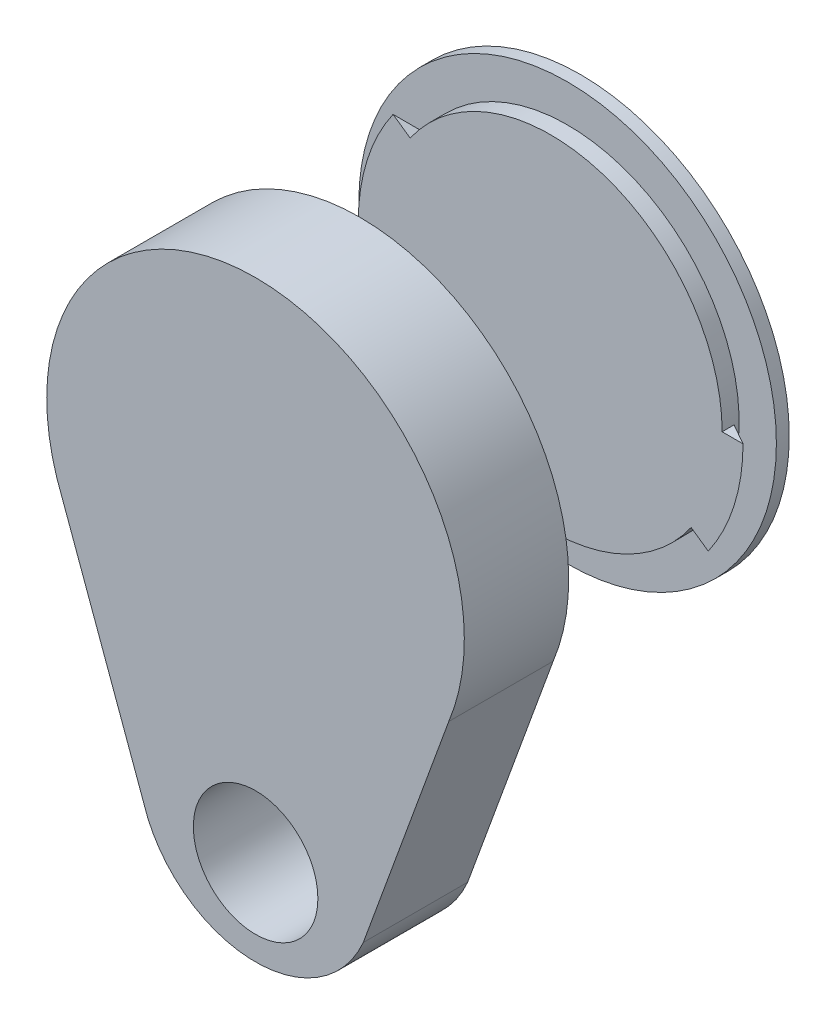
from build123d import *

# Parameters (mm, degrees)
BOSS_EXTRU_4_DEPTH           = 7
ESQUISSE11_R                 = 4.175305872
ENL_V_MAT_EXTRU_2_DEPTH      = 7
R_VOLUTION3_ANGLE            = 35
R_P_TITION_CIRCULAIRE1_COUNT = 2
R_VOLUTION4_ANGLE            = 140
R_P_TITION_CIRCULAIRE2_COUNT = 2


with BuildPart() as part:
    # Esquisse1 → Révolution1 (revolve)
    with BuildSketch(Plane(origin=(1.309044262, 0, 0), x_dir=(1, 0, 0), z_dir=(0, 1, 0))):
        Polygon((0.253488225, -3.046040946), (-13.746511775, -3.046040946), (-13.746511775, 3.953959054), (-12.746511775, 3.953959054), (-12.746511775, 3.442939457), (-12.746511775, 2.953959054), (-12.746511775, -2.046040946), (0.253488225, -2.046040946), align=None)
    revolve(axis=Axis((1.562532487, 0, 2.046040946), (0, 0, 1)))

    # Esquisse10 → Boss.-Extru.4 (add)
    with BuildSketch(Plane.XY.offset(3.046040946)):
        with BuildLine():
            Line((14.88883966, -4.290633652), (8.788835843, -21))
            ThreePointArc((8.788835843, -21), (1.562532487, -25.748246952), (-5.663770869, -21))
            Line((-5.663770869, -21), (-11.763774686, -4.290633652))
            ThreePointArc((-11.763774686, -4.290633652), (1.562532487, -13.260227708), (14.88883966, -4.290633652))
        make_face()
    extrude(amount=-BOSS_EXTRU_4_DEPTH)

    # Esquisse11 → Enlèv. mat.-Extru.2 (cut)
    with BuildSketch(Plane.XY.offset(3.046040946)):
        with Locations((1.568835843, -19.970784203)):
            Circle(ESQUISSE11_R)
    extrude(amount=-ENL_V_MAT_EXTRU_2_DEPTH, mode=Mode.SUBTRACT)

    # Esquisse14 → Révolution4 (revolve)
    with BuildSketch(Plane(origin=(0, 0, 0), x_dir=(1, 0, 0), z_dir=(0, 1, 0))):
        Polygon((-11.437467513, 3.953959054), (-9.937467513, 3.953959054), (-11.437467513, 3.153959054), align=None)
    r_volution4 = revolve(axis=Axis((1.562532487, 0, 2.046040946), (0, 0, -1)), revolution_arc=R_VOLUTION4_ANGLE)

    # Répétition circulaire2: Révolution4 ×2 about axis
    r_p_tition_circulaire2_axis = Axis((1.562532487, 0, 0), (0, 0, 1))
    for i in range(1, R_P_TITION_CIRCULAIRE2_COUNT):
        add(r_volution4.rotate(r_p_tition_circulaire2_axis, i * 360 / R_P_TITION_CIRCULAIRE2_COUNT))


with BuildPart() as body_2:
    # Esquisse2 → Révolution2 (revolve)
    with BuildSketch(Plane(origin=(0, 0, -11.80070304), x_dir=(1, 0, 0), z_dir=(0, 1, 0))):
        Polygon((0.663591956, 5.841333496), (-10.836408044, 5.841333496), (-10.836408044, 6.365484161), (-10.836408044, 6.97833407), (-13.336408044, 6.97833407), (-13.336408044, 7.841333496), (0.663591956, 7.841333496), align=None)
    revolve(axis=Axis((0.663591956, 0, -19.642036537), (0, 0, 1)))

    # Esquisse13 → Révolution3 (revolve)
    with BuildSketch(Plane(origin=(0, 0, 0), x_dir=(1, 0, 0), z_dir=(0, 1, 0))):
        Polygon((-10.836408044, 17.642036537), (-12.236408044, 17.642036537), (-10.836408044, 18.442036537), align=None)
    r_volution3 = revolve(axis=Axis((0.663591956, 0, -17.642036537), (0, 0, -1)), revolution_arc=R_VOLUTION3_ANGLE)

    # Répétition circulaire1: Révolution3 ×2 about axis
    r_p_tition_circulaire1_axis = Axis((0.663591956, 0, 0), (0, 0, 1))
    for i in range(1, R_P_TITION_CIRCULAIRE1_COUNT):
        add(r_volution3.rotate(r_p_tition_circulaire1_axis, i * 360 / R_P_TITION_CIRCULAIRE1_COUNT))


solid = Compound([part.part, body_2.part])
